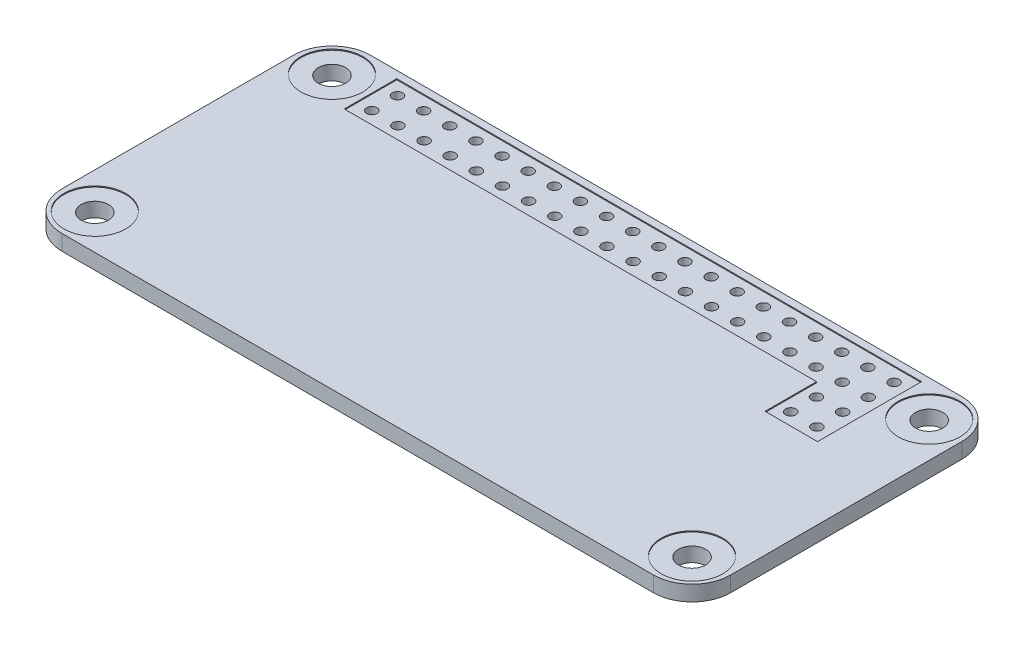
from build123d import *

# Parameters (mm, degrees)
BOSS_EXTRUDE1_DEPTH = 1.5
SKETCH2_R           = 1.325
CUT_EXTRUDE1_DEPTH  = 2.5
SKETCH3_R           = 0.5
CUT_EXTRUDE2_DEPTH  = 2.5
LPATTERN1_COUNT     = 20
LPATTERN1_PITCH     = 2.54
SKETCH5_R           = 0.5
CUT_EXTRUDE4_DEPTH  = 2.5
SKETCH4_R           = 3
CUT_EXTRUDE3_DEPTH  = 0.1


with BuildPart() as part:
    # Sketch1 → Boss-Extrude1 (new body)
    with BuildSketch(Plane(origin=(0, 0, 0), x_dir=(1, 0, 0), z_dir=(0, 1, 0))):
        with BuildLine():
            Line((-28.75, 15), (28.75, 15))
            ThreePointArc((28.75, 15), (31.401650429, 13.901650429), (32.5, 11.25))
            Line((32.5, 11.25), (32.5, -11.25))
            ThreePointArc((32.5, -11.25), (31.401650429, -13.901650429), (28.75, -15))
            Line((28.75, -15), (-28.75, -15))
            ThreePointArc((-28.75, -15), (-31.401650429, -13.901650429), (-32.5, -11.25))
            Line((-32.5, -11.25), (-32.5, 11.25))
            ThreePointArc((-32.5, 11.25), (-31.401650429, 13.901650429), (-28.75, 15))
        make_face()
    extrude(amount=BOSS_EXTRUDE1_DEPTH)

    # Sketch2 → Cut-Extrude1 (cut, through all)
    with BuildSketch(Plane(origin=(0, 1.5, 0), x_dir=(1, 0, 0), z_dir=(0, 1, 0))):
        with Locations((-29.025, 11.525)):
            Circle(SKETCH2_R)
        with Locations((29.025, 11.525)):
            Circle(SKETCH2_R)
        with Locations((29.025, -11.525)):
            Circle(SKETCH2_R)
        with Locations((-29.025, -11.525)):
            Circle(SKETCH2_R)
    extrude(amount=-CUT_EXTRUDE1_DEPTH, mode=Mode.SUBTRACT)

    # Sketch3 → Cut-Extrude2 (cut, through all)
    with BuildSketch(Plane(origin=(0, 1.5, 0), x_dir=(1, 0, 0), z_dir=(0, 1, 0))):
        with Locations((-24.128, 13)):
            Circle(SKETCH3_R)
        with Locations((-24.128, 10.5)):
            Circle(SKETCH3_R)
    cut_extrude2 = extrude(amount=-CUT_EXTRUDE2_DEPTH, mode=Mode.SUBTRACT)

    # LPattern1: Cut-Extrude2 ×20
    with Locations(*[(i * LPATTERN1_PITCH, 0, 0) for i in range(1, LPATTERN1_COUNT)]):
        add(cut_extrude2, mode=Mode.SUBTRACT)

    # Sketch5 → Cut-Extrude4 (cut, through all)
    with BuildSketch(Plane(origin=(0, 1.5, 0), x_dir=(1, 0, 0), z_dir=(0, 1, 0))):
        with Locations((21.592, 5.5)):
            Circle(SKETCH5_R)
        with Locations((24.132, 5.5)):
            Circle(SKETCH5_R)
        with Locations((21.592, 8)):
            Circle(SKETCH5_R)
        with Locations((24.132, 8)):
            Circle(SKETCH5_R)
    extrude(amount=-CUT_EXTRUDE4_DEPTH, mode=Mode.SUBTRACT)

    # Sketch4 → Cut-Extrude3 (cut)
    with BuildSketch(Plane(origin=(0, 1.5, 0), x_dir=(1, 0, 0), z_dir=(0, 1, 0))):
        with Locations((-29.025, 11.525)):
            Circle(SKETCH4_R)
        with Locations((-29.025, -11.525)):
            Circle(SKETCH4_R)
        with Locations((29.025, -11.525)):
            Circle(SKETCH4_R)
        with Locations((29.025, 11.525)):
            Circle(SKETCH4_R)
        Polygon((-25.5, 14.3), (25.5, 14.3), (25.5, 9.2), (25.5, 4.2), (20.4, 4.2), (20.4, 9.2), (-25.5, 9.2), align=None)
    extrude(amount=-CUT_EXTRUDE3_DEPTH, mode=Mode.SUBTRACT)


solid = part.part
